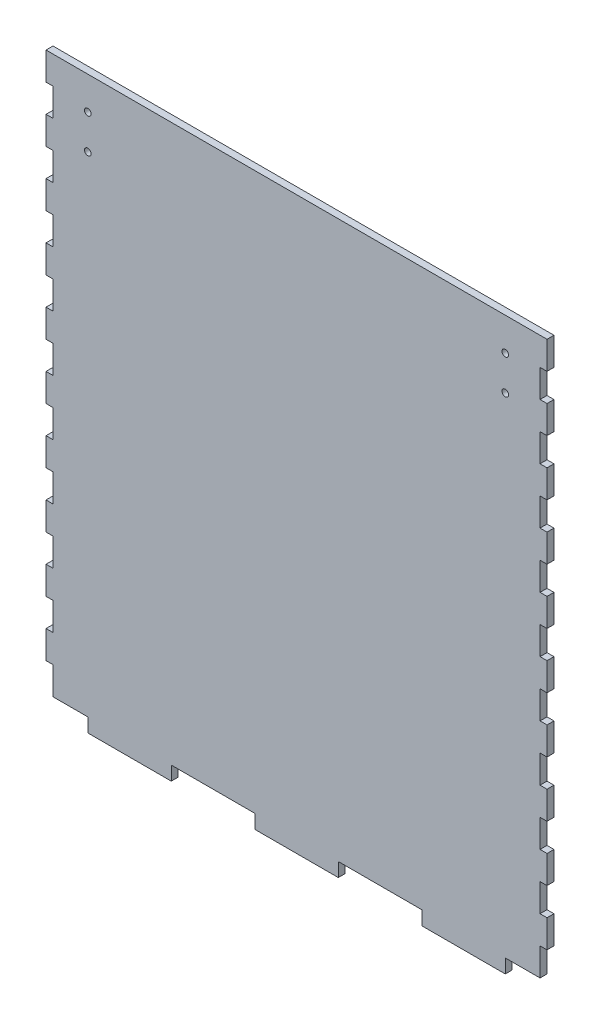
from build123d import *

# Parameters (mm, degrees)
BOSS_EXTRUDE1_DEPTH = 3.175
SKETCH3_R           = 1.5
CUT_EXTRUDE1_DEPTH  = 3.175


with BuildPart() as part:
    # Sketch1 → Boss-Extrude1 (new body)
    with BuildSketch(Plane.XY):
        Polygon((-114.3, 127), (-114.3, 114.3), (-111.125, 114.3), (-111.125, 101.6), (-114.3, 101.6), (-114.3, 88.9), (-111.125, 88.9), (-111.125, 76.2), (-114.3, 76.2), (-114.3, 63.5), (-111.125, 63.5), (-111.125, 50.8), (-114.3, 50.8), (-114.3, 38.1), (-111.125, 38.1), (-111.125, 25.4), (-114.3, 25.4), (-114.3, 12.7), (-111.125, 12.7), (-111.125, 0), (-114.3, 0), (-114.3, -12.7), (-111.125, -12.7), (-111.125, -25.4), (-114.3, -25.4), (-114.3, -38.1), (-111.125, -38.1), (-111.125, -50.8), (-114.3, -50.8), (-114.3, -63.5), (-111.125, -63.5), (-111.125, -76.2), (-114.3, -76.2), (-114.3, -88.9), (-111.125, -88.9), (-111.125, -101.6), (-114.3, -101.6), (-114.3, -114.3), (-111.125, -114.3), (-111.125, -127), (-95.25, -127), (-95.25, -133.35), (-57.15, -133.35), (-57.15, -127), (-19.05, -127), (-19.05, -133.35), (19.05, -133.35), (19.05, -127), (57.15, -127), (57.15, -133.35), (95.25, -133.35), (95.25, -127), (111.125, -127), (111.125, -114.3), (114.3, -114.3), (114.3, -101.6), (111.125, -101.6), (111.125, -88.9), (114.3, -88.9), (114.3, -76.2), (111.125, -76.2), (111.125, -63.5), (114.3, -63.5), (114.3, -50.8), (111.125, -50.8), (111.125, -38.1), (114.3, -38.1), (114.3, -25.4), (111.125, -25.4), (111.125, -12.7), (114.3, -12.7), (114.3, 0), (111.125, 0), (111.125, 12.7), (114.3, 12.7), (114.3, 25.4), (111.125, 25.4), (111.125, 38.1), (114.3, 38.1), (114.3, 50.8), (111.125, 50.8), (111.125, 63.5), (114.3, 63.5), (114.3, 76.2), (111.125, 76.2), (111.125, 88.9), (114.3, 88.9), (114.3, 101.6), (111.125, 101.6), (111.125, 114.3), (114.3, 114.3), (114.3, 127), align=None)
    extrude(amount=BOSS_EXTRUDE1_DEPTH)

    # Sketch3 → Cut-Extrude1 (cut)
    with BuildSketch(Plane(origin=(0, 0, 0), x_dir=(-1, 0, 0), z_dir=(0, 0, -1))):
        with Locations((-95.25, 112)):
            Circle(SKETCH3_R)
        with Locations((-95.25, 96.25)):
            Circle(SKETCH3_R)
        with Locations((95.25, 96.25)):
            Circle(SKETCH3_R)
        with Locations((95.25, 112)):
            Circle(SKETCH3_R)
    extrude(amount=-CUT_EXTRUDE1_DEPTH, mode=Mode.SUBTRACT)


solid = part.part
